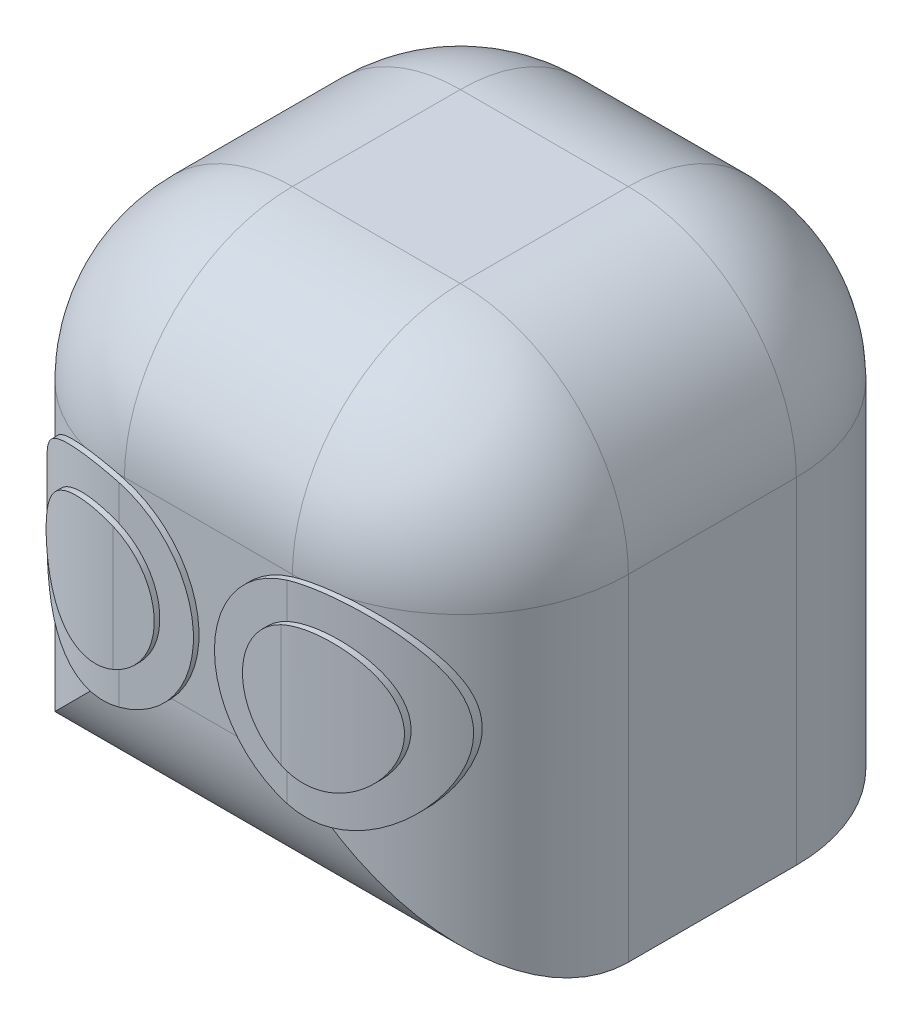
from build123d import *

# Parameters (mm, degrees)
CROQUIS1_W                   = 90
CROQUIS1_H                   = 90
SALIENTE_EXTRUIR1_DEPTH      = 90
REDONDEO2_R                  = 30
CROQUIS2_R                   = 18
SALIENTE_EXTRUIR2_DEPTH      = 1
SALIENTE_EXTRUIR2_DEPTH_BACK = 12
CORTAR_EXTRUIR1_DEPTH        = 74
CROQUIS4_R                   = 12
SALIENTE_EXTRUIR3_DEPTH      = 1
SALIENTE_EXTRUIR3_DEPTH_BACK = 6
CORTAR_EXTRUIR2_DEPTH        = 100


with BuildPart() as part:
    # Croquis1 → Saliente-Extruir1 (new body)
    with BuildSketch(Plane.XY):
        with Locations((-11.750768053, -2.707538995)):
            Rectangle(CROQUIS1_W, CROQUIS1_H)
    extrude(amount=SALIENTE_EXTRUIR1_DEPTH)

    # Redondeo2
    redondeo2_edges = [part.edges().sort_by_distance(p)[0] for p in [
        (33.249231947, -2.707538995, 90),
        (-11.750768053, 42.292461005, 90),
        (-56.750768053, -2.707538995, 90),
        (-11.750768053, 42.292461005, 0),
        (33.249231947, -2.707538995, 0),
        (-56.750768053, -2.707538995, 0),
        (-11.750768053, -47.707538995, 90),
        (-56.750768053, 42.292461005, 45),
        (33.249231947, 42.292461005, 45),
    ]]
    fillet(redondeo2_edges, radius=REDONDEO2_R)

    # Croquis2 → Saliente-Extruir2 (add, two sides)
    with BuildSketch(Plane.XY.offset(90)) as saliente_extruir2_sk:
        with Locations((8.324186068, -5.35884863)):
            Circle(CROQUIS2_R)
        with Locations((-31.428963697, -5.35884863)):
            Circle(CROQUIS2_R)
    extrude(amount=SALIENTE_EXTRUIR2_DEPTH)
    extrude(saliente_extruir2_sk.sketch, amount=-SALIENTE_EXTRUIR2_DEPTH_BACK)

    # Croquis3 → Cortar-Extruir1 (cut)
    with BuildSketch(Plane(origin=(0, 42.292461005, 0), x_dir=(1, 0, 0), z_dir=(0, 1, 0))):
        with BuildLine():
            ThreePointArc((-50.140421134, -80.34512543), (-39.601859674, -88.210803678), (-26.750768053, -91))
            Line((-26.750768053, -91), (-50.140421134, -91))
            Line((-50.140421134, -91), (-50.140421134, -80.34512543))
        make_face()
        with BuildLine():
            Line((26.638885028, -91), (26.638885028, -80.34512543))
            ThreePointArc((26.638885028, -80.34512543), (16.100323567, -88.210803678), (3.249231947, -91))
            Line((3.249231947, -91), (26.638885028, -91))
        make_face()
    extrude(amount=-CORTAR_EXTRUIR1_DEPTH, mode=Mode.SUBTRACT)

    # Croquis4 → Saliente-Extruir3 (add, two sides)
    with BuildSketch(Plane.XY.offset(91)) as saliente_extruir3_sk:
        with Locations((-31.428963697, -5.35884863)):
            Circle(CROQUIS4_R)
        with Locations((8.324186068, -5.35884863)):
            Circle(CROQUIS4_R)
    extrude(amount=SALIENTE_EXTRUIR3_DEPTH)
    extrude(saliente_extruir3_sk.sketch, amount=-SALIENTE_EXTRUIR3_DEPTH_BACK)

    # Croquis5 → Cortar-Extruir2 (cut)
    with BuildSketch(Plane(origin=(0, 42.292461005, 0), x_dir=(1, 0, 0), z_dir=(0, 1, 0))):
        with BuildLine():
            ThreePointArc((-48.087335127, -83.84849902), (-38.171101485, -89.892741332), (-26.750768053, -92))
            Line((-26.750768053, -92), (-43.428963697, -92))
            Line((-43.428963697, -92), (-48.087335127, -92))
            Line((-48.087335127, -92), (-48.087335127, -83.84849902))
        make_face()
        with BuildLine():
            ThreePointArc((24.585799021, -83.84849902), (14.669565378, -89.892741332), (3.249231947, -92))
            Line((3.249231947, -92), (19.927427591, -92))
            Line((19.927427591, -92), (24.585799021, -92))
            Line((24.585799021, -92), (24.585799021, -83.84849902))
        make_face()
    extrude(amount=-CORTAR_EXTRUIR2_DEPTH, mode=Mode.SUBTRACT)


solid = part.part
